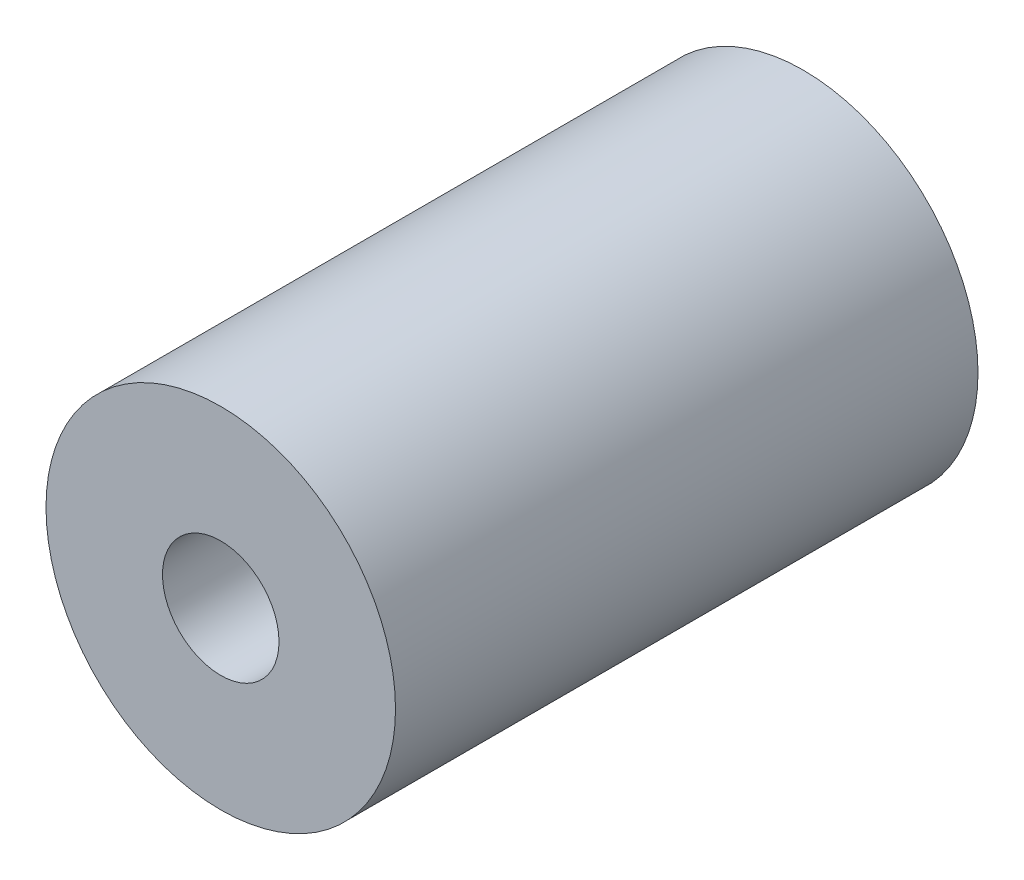
from build123d import *

# Parameters (mm, degrees)
SKETCH1_R           = 3
SKETCH1_R_2         = 1
EXTRUDE_THIN1_DEPTH = 10


with BuildPart() as part:
    # Sketch1 → Extrude-Thin1 (new body)
    with BuildSketch(Plane.XY):
        Circle(SKETCH1_R)
        Circle(SKETCH1_R_2, mode=Mode.SUBTRACT)
    extrude(amount=EXTRUDE_THIN1_DEPTH)


solid = part.part
